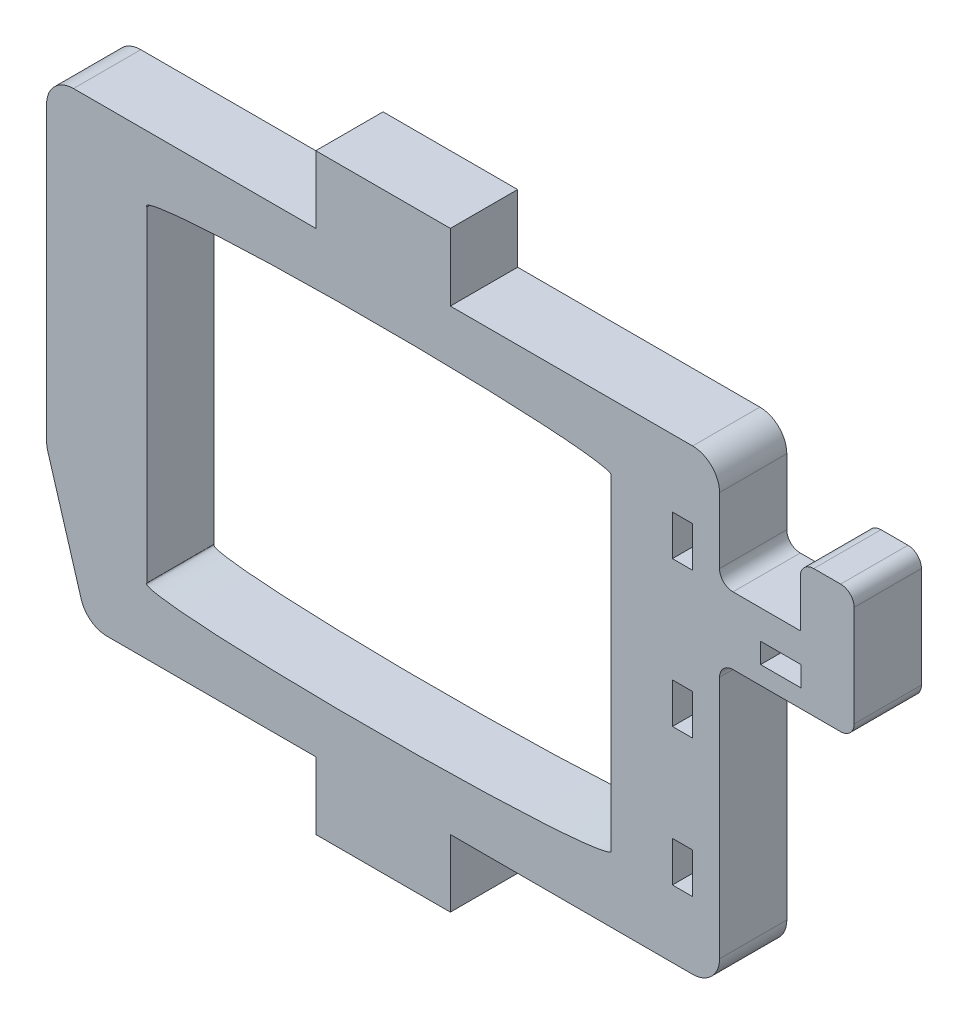
from build123d import *

# Parameters (mm, degrees)
RESSALTO_EXTRUS_O1_DEPTH = 5
CORTE_EXTRUS_O1_DEPTH    = 6
FILETE1_R                = 2
CORTE_EXTRUS_O2_DEPTH    = 6.0000001
FILETE2_R                = 2
ESBO_O4_W                = 1.5
ESBO_O4_H                = 3
CORTE_EXTRUS_O3_DEPTH    = 6.0000001
ESBO_O5_W                = 5
ESBO_O5_H                = 5
RESSALTO_EXTRUS_O2_DEPTH = 10
ESBO_O6_W                = 4
ESBO_O6_H                = 5
RESSALTO_EXTRUS_O3_DEPTH = 4.5
ESBO_O7_W                = 3
ESBO_O7_H                = 1.5
CORTE_EXTRUS_O4_DEPTH    = 6.0000001
FILETE3_R                = 1


with BuildPart() as part:
    # Esboço1 → Ressalto-extrusão1 (new body)
    with BuildSketch(Plane.XY):
        Polygon((-5, 0), (15, 0), (15, -5), (25, -5), (25, 0), (45, 0), (45, 34), (25, 34), (25, 39), (15, 39), (15, 34), (-5, 34), align=None)
    extrude(amount=RESSALTO_EXTRUS_O1_DEPTH)

    # Esboço2 → Corte-extrusão1 (cut, through all)
    with BuildSketch(Plane.XY.offset(5)):
        with BuildLine():
            Line((2.44644355, 4.9), (2.44644355, 29.1))
            add(Edge.make_bspline(
                [(36.94644355, 29.1), (36.948002105, 30.126549864), (19.233916272, 30.126549864), (1.51983044, 30.126549864), (2.44644355, 29.1)],
                knots=[0, 0, 0, 1.596998014, 1.596998014, 3.193996028, 3.193996028, 3.193996028], degree=2, weights=[1, 0.697782671, 1, 0.697782671, 1]))
            Line((36.94644355, 29.1), (36.94644355, 4.9))
            add(Edge.make_bspline(
                [(2.44644355, 4.9), (1.51983044, 3.873450136), (19.233916272, 3.873450136), (36.948002105, 3.873450136), (36.94644355, 4.9)],
                knots=[3.089189279, 3.089189279, 3.089189279, 4.686187293, 4.686187293, 6.283185307, 6.283185307, 6.283185307], degree=2, weights=[1, 0.697782671, 1, 0.697782671, 1]))
        make_face()
    extrude(amount=-CORTE_EXTRUS_O1_DEPTH, mode=Mode.SUBTRACT)

    # Filete1
    filete1_edges = [part.edges().sort_by_distance(p)[0] for p in [
        (-5, 34, 2.5),
        (45, 34, 2.5),
        (45, 0, 2.5),
    ]]
    fillet(filete1_edges, radius=FILETE1_R)

    # Esboço3 → Corte-extrusão2 (cut, through all)
    with BuildSketch(Plane.XY.offset(5)):
        Polygon((-5, 10), (-2, 0), (-5, 0), align=None)
    extrude(amount=-CORTE_EXTRUS_O2_DEPTH, mode=Mode.SUBTRACT)

    # Filete2
    filete2_edges = [part.edges().sort_by_distance(p)[0] for p in [
        (-5, 10, 2.5),
        (-2, 0, 2.5),
    ]]
    fillet(filete2_edges, radius=FILETE2_R)

    # Esboço4 → Corte-extrusão3 (cut, through all)
    with BuildSketch(Plane(origin=(0, 0, 0), x_dir=(-1, 0, 0), z_dir=(0, 0, -1))):
        with Locations((-42.25, 27.5)):
            Rectangle(ESBO_O4_W, ESBO_O4_H)
        with Locations((-42.25, 16.699542108)):
            Rectangle(ESBO_O4_W, ESBO_O4_H)
        with Locations((-42.25, 6.5)):
            Rectangle(ESBO_O4_W, ESBO_O4_H)
    extrude(amount=-CORTE_EXTRUS_O3_DEPTH, mode=Mode.SUBTRACT)

    # Esboço5 → Ressalto-extrusão2 (add)
    with BuildSketch(Plane(origin=(45, 0, 0), x_dir=(0, 0, -1), z_dir=(1, 0, 0))):
        with Locations((-2.5, 23.61133512)):
            Rectangle(ESBO_O5_W, ESBO_O5_H)
    extrude(amount=RESSALTO_EXTRUS_O2_DEPTH)

    # Esboço6 → Ressalto-extrusão3 (add)
    with BuildSketch(Plane(origin=(0, 26.11133512, 0), x_dir=(1, 0, 0), z_dir=(0, 1, 0))):
        with Locations((53, -2.5)):
            Rectangle(ESBO_O6_W, ESBO_O6_H)
    extrude(amount=RESSALTO_EXTRUS_O3_DEPTH)

    # Esboço7 → Corte-extrusão4 (cut, through all)
    with BuildSketch(Plane.XY.offset(5)):
        with Locations((49.550379902, 23.207612691)):
            Rectangle(ESBO_O7_W, ESBO_O7_H)
    extrude(amount=-CORTE_EXTRUS_O4_DEPTH, mode=Mode.SUBTRACT)

    # Filete3
    filete3_edges = [part.edges().sort_by_distance(p)[0] for p in [
        (45, 21.11133512, 2.5),
        (45, 26.11133512, 2.5),
        (55, 21.11133512, 2.5),
        (55, 30.61133512, 2.5),
        (51, 30.61133512, 2.5),
    ]]
    fillet(filete3_edges, radius=FILETE3_R)


solid = part.part
